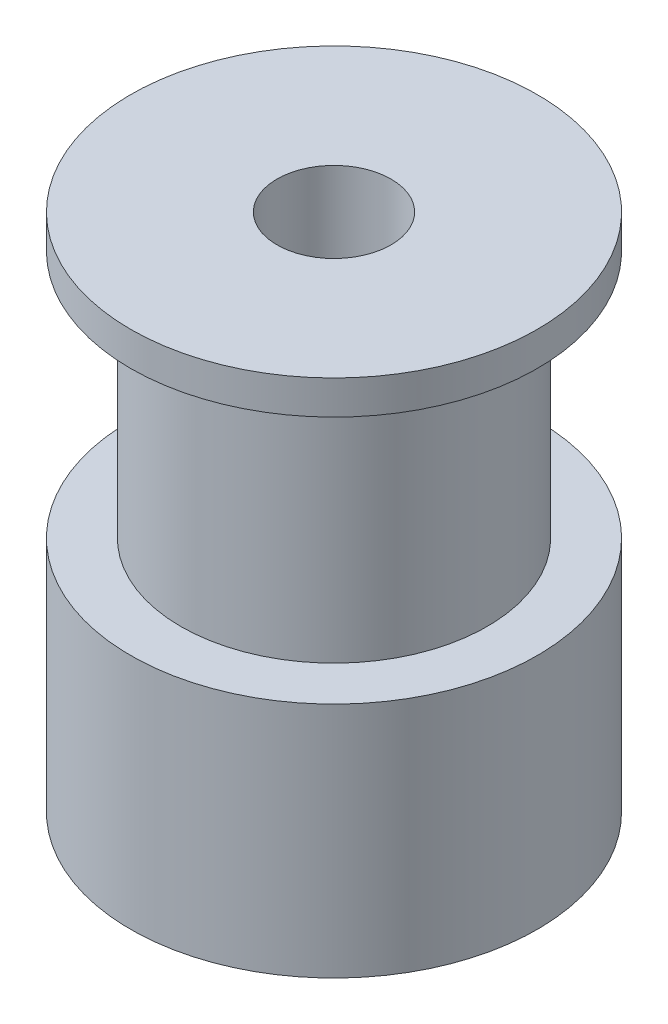
from build123d import *

# Parameters (mm, degrees)
SKETCH_1_R            = 6.78
EXTRUDE_2_DEPTH       = 11
SKETCH_3_R            = 9
EXTRUDE_355_DEPTH     = 1.5
SKETCH_4_R            = 9
EXTRUDE_447_DEPTH     = 10.5
SKETCH_5_R            = 2.525
CUT_EXTRUDE_536_DEPTH = 24


with BuildPart() as part:
    # 草图1 → 凸台-拉伸2 (new body)
    with BuildSketch(Plane(origin=(0, 0, 0), x_dir=(1, 0, 0), z_dir=(0, 1, 0))):
        Circle(SKETCH_1_R)
    extrude(amount=EXTRUDE_2_DEPTH)

    # 草图3 → Extrude 355 (add)
    with BuildSketch(Plane(origin=(0, 11, 0), x_dir=(1, 0, 0), z_dir=(0, 1, 0))):
        Circle(SKETCH_3_R)
    extrude(amount=EXTRUDE_355_DEPTH)

    # 草图4 → Extrude 447 (add)
    with BuildSketch(Plane.XZ):
        Circle(SKETCH_4_R)
    extrude(amount=EXTRUDE_447_DEPTH)

    # 草图5 → Cut-Extrude 536 (cut, through all)
    with BuildSketch(Plane.XZ.offset(10.5)):
        Circle(SKETCH_5_R)
    extrude(amount=-CUT_EXTRUDE_536_DEPTH, mode=Mode.SUBTRACT)


solid = part.part
